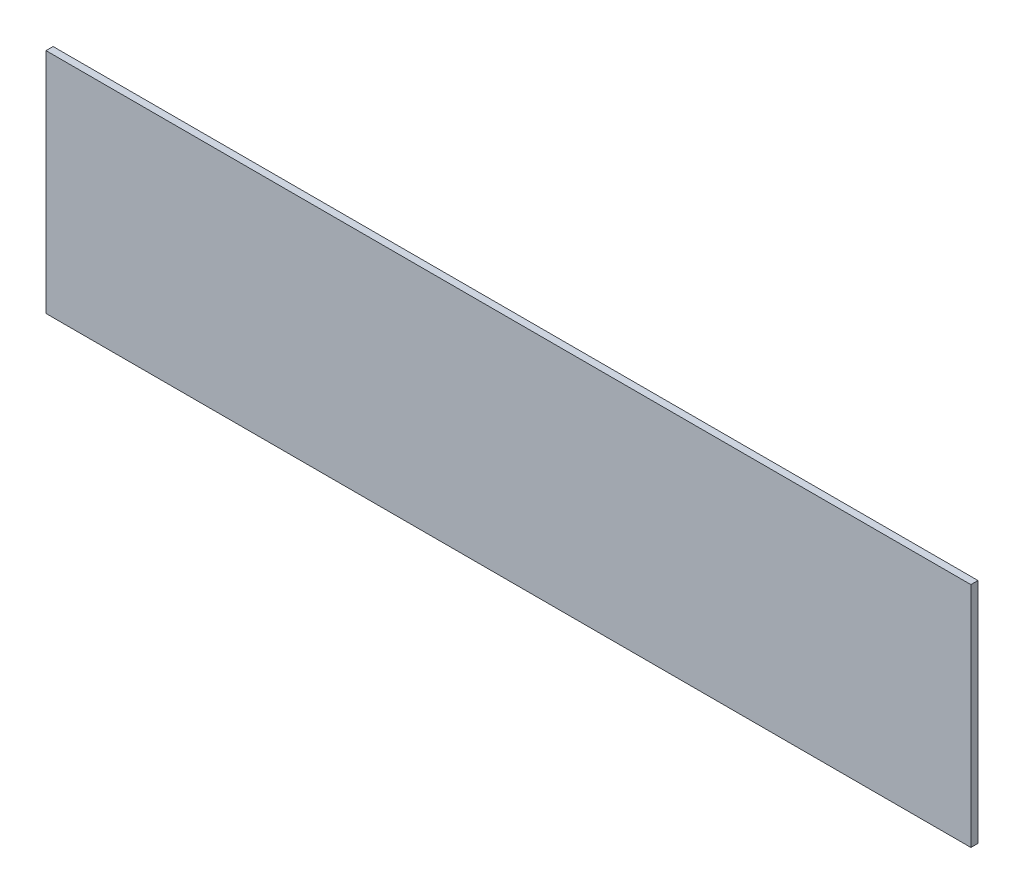
from build123d import *

# Parameters (mm, degrees)
CROQUIS1_W              = 260
CROQUIS1_H              = 64
SALIENTE_EXTRUIR1_DEPTH = 2


with BuildPart() as part:
    # Croquis1 → Saliente-Extruir1 (new body)
    with BuildSketch(Plane.XY):
        Rectangle(CROQUIS1_W, CROQUIS1_H)
    extrude(amount=SALIENTE_EXTRUIR1_DEPTH)


solid = part.part
